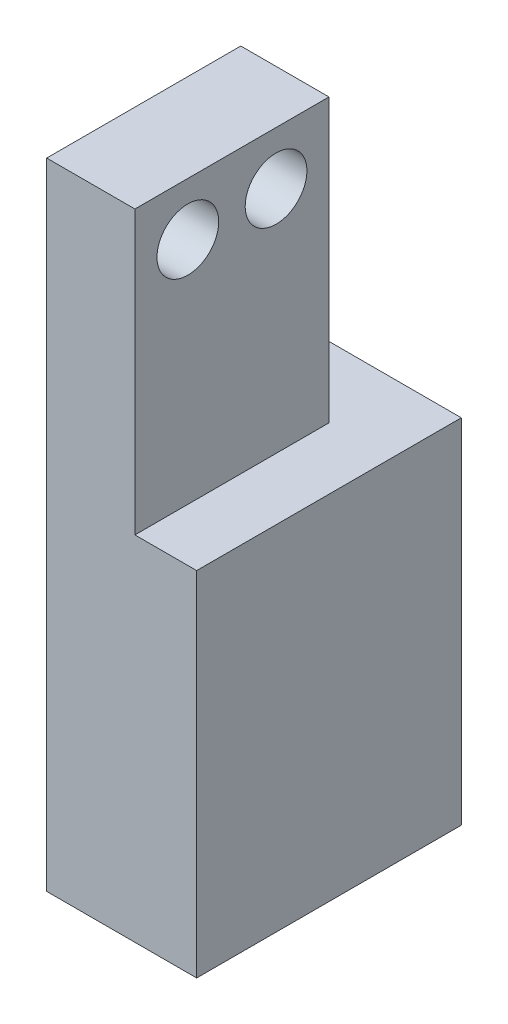
from build123d import *

# Parameters (mm, degrees)
BOSS_EXTRUDE1_DEPTH = 15
SKETCH2_W           = 5
SKETCH2_H           = 4
CUT_EXTRUDE1_DEPTH  = 16
SKETCH7_R           = 1.75
CUT_EXTRUDE3_DEPTH  = 6


with BuildPart() as part:
    # Sketch1 → Boss-Extrude1 (new body)
    with BuildSketch(Plane.XY):
        Polygon((0, 36), (0, 0), (8.5, 0), (8.5, 20), (5, 20), (5, 36), align=None)
    extrude(amount=-BOSS_EXTRUDE1_DEPTH)

    # Sketch2 → Cut-Extrude1 (cut)
    with BuildSketch(Plane(origin=(0, 36, 0), x_dir=(1, 0, 0), z_dir=(0, 1, 0))):
        with Locations((2.5, 13)):
            Rectangle(SKETCH2_W, SKETCH2_H)
    extrude(amount=-CUT_EXTRUDE1_DEPTH, mode=Mode.SUBTRACT)

    # Sketch7 → Cut-Extrude3 (cut, through all)
    with BuildSketch(Plane(origin=(5, 0, 0), x_dir=(0, 0, -1), z_dir=(1, 0, 0))):
        with Locations((3, 33)):
            Circle(SKETCH7_R)
        with Locations((8, 33)):
            Circle(SKETCH7_R)
    extrude(amount=-CUT_EXTRUDE3_DEPTH, mode=Mode.SUBTRACT)


solid = part.part
